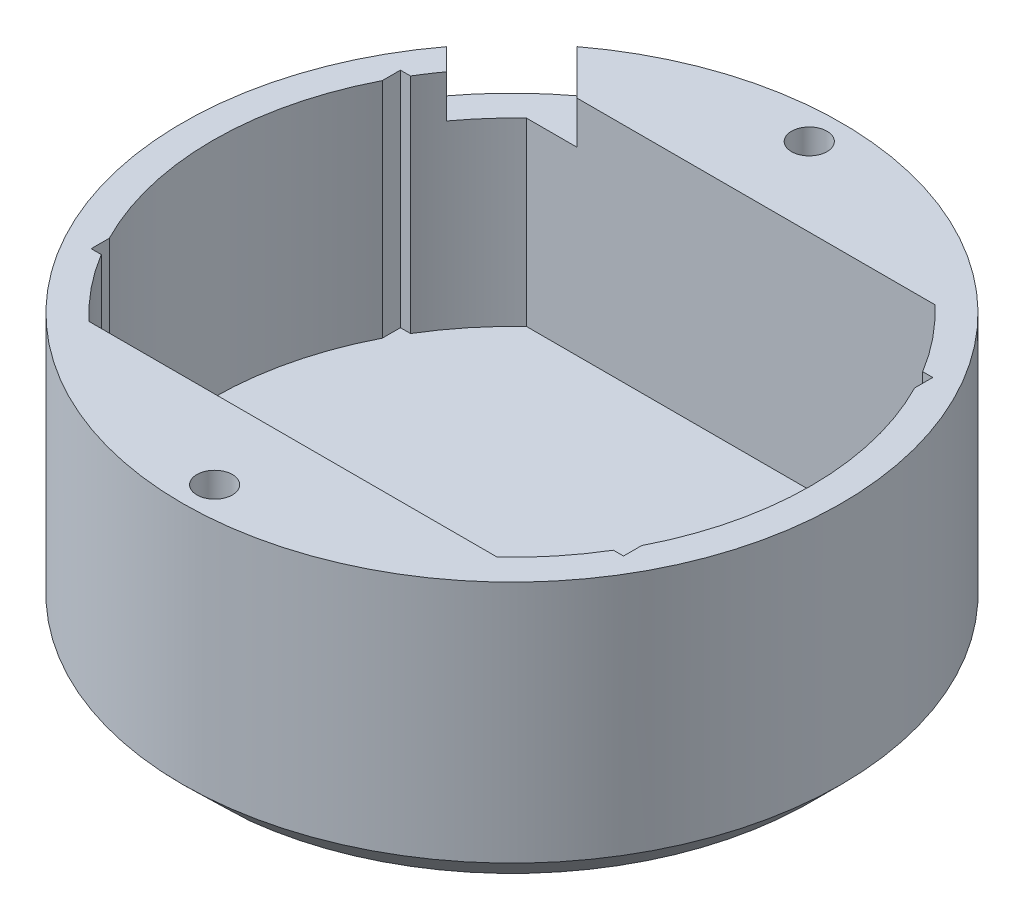
from build123d import *

# Parameters (mm, degrees)
SKETCH2_R           = 32.5
BOSS_EXTRUDE1_DEPTH = 27
SKETCH3_R           = 29.5
CUT_EXTRUDE1_DEPTH  = 22
CHAMFER1_SIZE       = 3
BOSS_EXTRUDE2_DEPTH = 22
SKETCH6_W           = 52.5
SKETCH6_H           = 30.5
CUT_EXTRUDE3_DEPTH  = 23
CUT_EXTRUDE4_DEPTH  = 6
SKETCH12_W          = 4.2
SKETCH12_H          = 9.1
CUT_EXTRUDE5_DEPTH  = 10
SKETCH4_R           = 1.75
CUT_EXTRUDE2_DEPTH  = 28


with BuildPart() as part:
    # Sketch2 → Boss-Extrude1 (new body)
    with BuildSketch(Plane(origin=(0, 0, 0), x_dir=(1, 0, 0), z_dir=(0, 1, 0))):
        Circle(SKETCH2_R)
    extrude(amount=-BOSS_EXTRUDE1_DEPTH)

    # Sketch3 → Cut-Extrude1 (cut)
    with BuildSketch(Plane(origin=(0, 0, 0), x_dir=(1, 0, 0), z_dir=(0, 1, 0))):
        Circle(SKETCH3_R)
    extrude(amount=-CUT_EXTRUDE1_DEPTH, mode=Mode.SUBTRACT)

    # Chamfer1
    chamfer1_edges = [part.edges().sort_by_distance(p)[0] for p in [
        (-32.5, -27, 0),
    ]]
    chamfer(chamfer1_edges, length=CHAMFER1_SIZE)

    # Sketch5 → Boss-Extrude2 (add)
    with BuildSketch(Plane(origin=(0, 0, 0), x_dir=(1, 0, 0), z_dir=(0, 1, 0))):
        with BuildLine():
            Line((20.124241601, -21.57), (-20.124241601, -21.57))
            ThreePointArc((-20.124241601, -21.57), (0, -29.5), (20.124241601, -21.57))
        make_face()
    boss_extrude2 = extrude(amount=-BOSS_EXTRUDE2_DEPTH)

    # Sketch6 → Cut-Extrude3 (cut, through all)
    with BuildSketch(Plane(origin=(0, -22, 0), x_dir=(1, 0, 0), z_dir=(0, 1, 0))):
        Rectangle(SKETCH6_W, SKETCH6_H)
    extrude(amount=CUT_EXTRUDE3_DEPTH, mode=Mode.SUBTRACT)

    # Mirror1: Boss-Extrude2 across plane
    add(boss_extrude2.mirror(Plane.XY))

    # Sketch10 → Cut-Extrude4 (cut)
    with BuildSketch(Plane.XZ.offset(27)):
        Polygon((-1.732050808, -32.32), (1.732050808, -32.32), (3.464101615, -29.32), (1.732050808, -26.32), (-1.732050808, -26.32), (-3.464101615, -29.32), align=None)
        Polygon((-3.464101615, 29.32), (-1.732050808, 32.32), (1.732050808, 32.32), (3.464101615, 29.32), (1.732050808, 26.32), (-1.732050808, 26.32), align=None)
    extrude(amount=-CUT_EXTRUDE4_DEPTH, mode=Mode.SUBTRACT)

    # Sketch12 → Cut-Extrude5 (cut)
    with BuildSketch(Plane(origin=(-22.980970389, 0, -22.980970389), x_dir=(0, 1, 0), z_dir=(-0.707106781, 0, -0.707106781))):
        with Locations((-2.1, 0)):
            Rectangle(SKETCH12_W, SKETCH12_H)
    extrude(amount=-CUT_EXTRUDE5_DEPTH, mode=Mode.SUBTRACT)

    # Sketch4 → Cut-Extrude2 (cut, through all)
    with BuildSketch(Plane(origin=(0, 0, 0), x_dir=(1, 0, 0), z_dir=(0, 1, 0))):
        with Locations((0, 29.32)):
            Circle(SKETCH4_R)
        with Locations((0, -29.32)):
            Circle(SKETCH4_R)
    extrude(amount=-CUT_EXTRUDE2_DEPTH, mode=Mode.SUBTRACT)


solid = part.part
